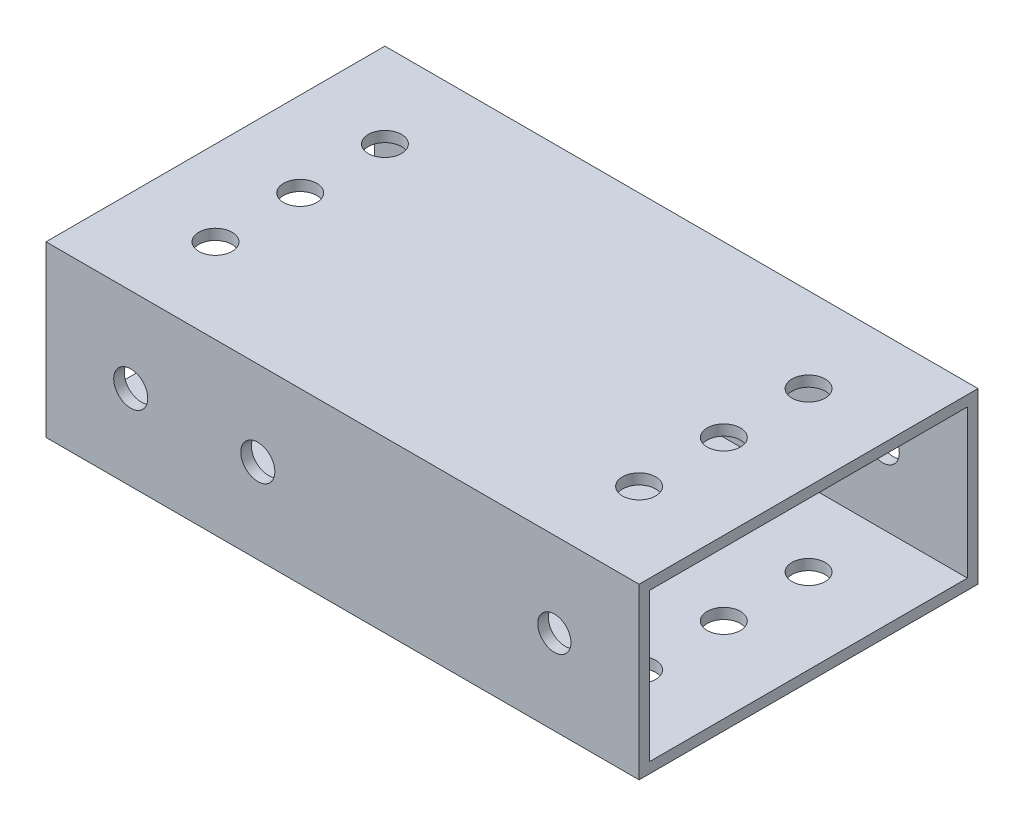
from build123d import *

# Parameters (mm, degrees)
SKETCH1_W           = 50.8
SKETCH1_H           = 25.4
BOSS_EXTRUDE1_DEPTH = 44.45
SHELL1_T            = -1.5875
SKETCH2_R           = 2.4892
CUT_EXTRUDE1_DEPTH  = 26.4
SKETCH3_R           = 2.4892
CUT_EXTRUDE2_DEPTH  = 51.8
SKETCH4_R           = 2.5527
CUT_EXTRUDE3_DEPTH  = 51.8
CUT_EXTRUDE4_REACH  = 52.8
SKETCH5_R           = 2.5527


with BuildPart() as part:
    # Sketch1 → Boss-Extrude1 (new body, symmetric)
    with BuildSketch(Plane(origin=(0, 0, 0), x_dir=(0, 0, -1), z_dir=(1, 0, 0))):
        with Locations((25.4, 12.7)):
            Rectangle(SKETCH1_W, SKETCH1_H)
    extrude(amount=BOSS_EXTRUDE1_DEPTH, both=True)

    # Shell1
    shell1_openings = [part.faces().sort_by_distance(p)[0] for p in [
        (44.45, 12.7, -25.4),
        (-44.45, 12.7, -25.4),
    ]]
    offset(amount=SHELL1_T, openings=shell1_openings, kind=Kind.INTERSECTION)

    # Sketch2 → Cut-Extrude1 (cut, through all)
    with BuildSketch(Plane(origin=(0, 25.4, 0), x_dir=(1, 0, 0), z_dir=(0, 1, 0))):
        with Locations((-31.75, 25.4)):
            Circle(SKETCH2_R)
        with Locations((-31.75, 12.7)):
            Circle(SKETCH2_R)
        with Locations((-31.75, 38.1)):
            Circle(SKETCH2_R)
    cut_extrude1 = extrude(amount=-CUT_EXTRUDE1_DEPTH, mode=Mode.SUBTRACT)

    # Sketch3 → Cut-Extrude2 (cut, through all)
    with BuildSketch(Plane.XY):
        with Locations((-31.75, 12.7)):
            Circle(SKETCH3_R)
    cut_extrude2 = extrude(amount=-CUT_EXTRUDE2_DEPTH, mode=Mode.SUBTRACT)

    # Mirror1: Cut-Extrude1, Cut-Extrude2 across plane
    add(cut_extrude1.mirror(Plane(origin=(0, 0, 0), x_dir=(0, 0, 1), z_dir=(1, 0, 0))), mode=Mode.SUBTRACT)
    add(cut_extrude2.mirror(Plane(origin=(0, 0, 0), x_dir=(0, 0, 1), z_dir=(1, 0, 0))), mode=Mode.SUBTRACT)

    # Sketch4 → Cut-Extrude3 (cut, through all)
    with BuildSketch(Plane.XY):
        with Locations((-12.7, 12.7)):
            Circle(SKETCH4_R)
    extrude(amount=-CUT_EXTRUDE3_DEPTH, mode=Mode.SUBTRACT)

    # Sketch5 → Cut-Extrude4 (cut, up to next)
    with BuildSketch(Plane.XY, mode=Mode.PRIVATE) as cut_extrude4_sk1:
        with Locations((-31.75, 12.7)):
            Circle(SKETCH5_R)
    cut_extrude4_tool1 = extrude(cut_extrude4_sk1.sketch, amount=-CUT_EXTRUDE4_REACH, mode=Mode.PRIVATE) & part.part
    add(cut_extrude4_tool1.solids().sort_by_distance((-31.75, 12.7, 0))[0], mode=Mode.SUBTRACT)


solid = part.part
